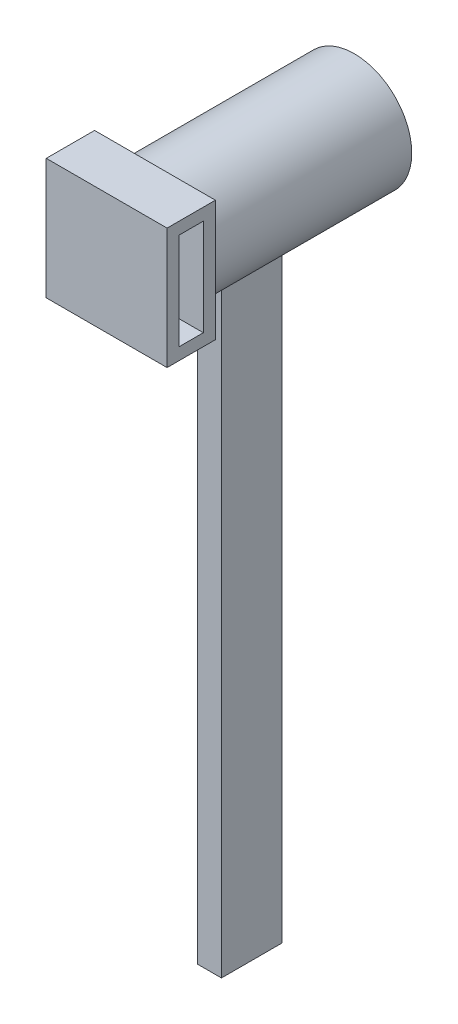
from build123d import *

# Parameters (mm, degrees)
SKETCH2_R               = 4.75
SKETCH3_R               = 4.75
SKETCH4_W               = 2
SKETCH4_H               = 5
BOSS_EXTRUDE1_DEPTH     = 55
SKETCH3_7_W             = 10
SKETCH3_7_H             = 10
BOSS_EXTRUDE4_DEPTH     = 4
CUT_EXTRUDE2_DEPTH      = 60.542001982
CUT_EXTRUDE2_DEPTH_BACK = 60.542001982
SKETCH8_W               = 2
SKETCH8_H               = 8


with BuildPart() as part:
    # Sketch2 → Loft1 section 0
    with BuildSketch(Plane.XY):
        Circle(SKETCH2_R)
    # Sketch3 → Loft1 section 1
    with BuildSketch(Plane.XY.offset(16.5)):
        Circle(SKETCH3_R)
    loft()

    # Sketch4 → Boss-Extrude1 (add)
    with BuildSketch(Plane(origin=(0, 0, 0), x_dir=(1, 0, 0), z_dir=(0, 1, 0))):
        with Locations((0, -9.5)):
            Rectangle(SKETCH4_W, SKETCH4_H)
    extrude(amount=-BOSS_EXTRUDE1_DEPTH)

    # Sketch3_7 → Boss-Extrude4 (add)
    with BuildSketch(Plane.XY.offset(16.5)):
        Rectangle(SKETCH3_7_W, SKETCH3_7_H)
    extrude(amount=BOSS_EXTRUDE4_DEPTH)

    # Sketch8 → Cut-Extrude2 (cut, two sides: drawn at the far end of the back side and taken through both)
    with BuildSketch(Plane(origin=(5, 0, 0), x_dir=(0, 0, -1), z_dir=(1, 0, 0)).offset(-CUT_EXTRUDE2_DEPTH_BACK)):
        with Locations((-18.5, 0)):
            Rectangle(SKETCH8_W, SKETCH8_H)
    extrude(amount=CUT_EXTRUDE2_DEPTH + CUT_EXTRUDE2_DEPTH_BACK, mode=Mode.SUBTRACT)


solid = part.part
